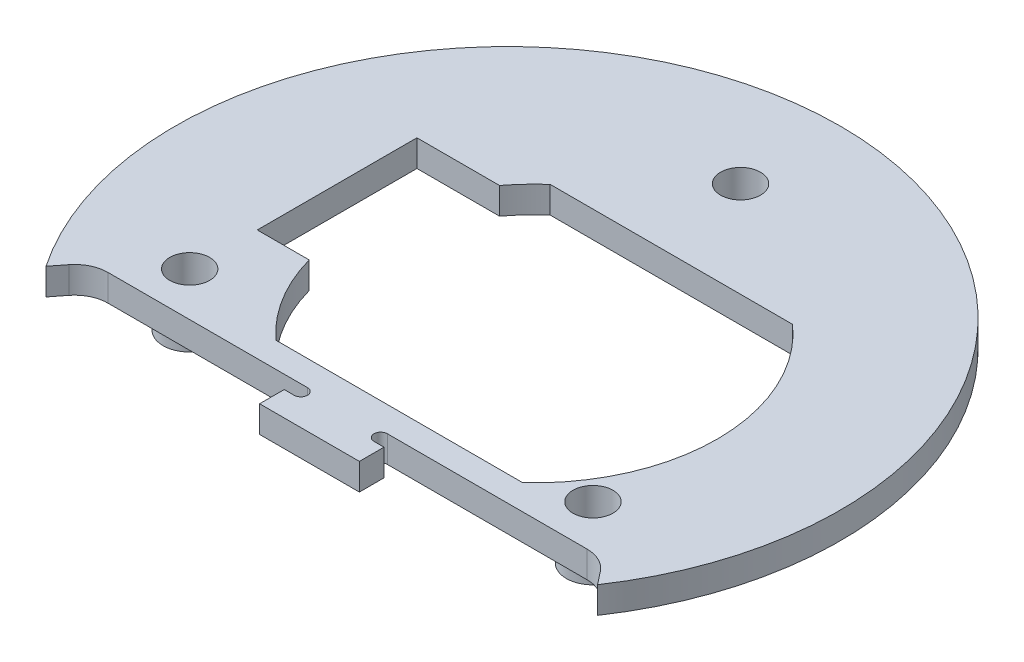
from build123d import *

# Parameters (mm, degrees)
SKETCH1_R           = 50
BOSS_EXTRUDE1_DEPTH = 4
CUT_EXTRUDE1_START  = -1
SKETCH2_R           = 3
CUT_EXTRUDE1_DEPTH  = 6
CIRPATTERN1_COUNT   = 3
SKETCH3_R           = 4
BOSS_EXTRUDE3_DEPTH = 4
SKETCH4_R           = 3
CUT_EXTRUDE2_DEPTH  = 5
CIRPATTERN2_COUNT   = 3
CUT_EXTRUDE4_DEPTH  = 5
CUT_EXTRUDE5_DEPTH  = 9


with BuildPart() as part:
    # Sketch1 → Boss-Extrude1 (new body)
    with BuildSketch(Plane(origin=(0, 0, 0), x_dir=(1, 0, 0), z_dir=(0, 1, 0))):
        Circle(SKETCH1_R)
    extrude(amount=BOSS_EXTRUDE1_DEPTH)

    # Sketch2 → Cut-Extrude1 (cut)
    with BuildSketch(Plane(origin=(0, 0, 0), x_dir=(1, 0, 0), z_dir=(0, 1, 0)).offset(CUT_EXTRUDE1_START)):
        with Locations((0, 35)):
            Circle(SKETCH2_R)
    cut_extrude1 = extrude(amount=CUT_EXTRUDE1_DEPTH, mode=Mode.SUBTRACT)

    # CirPattern1: Cut-Extrude1 ×3 about axis
    cirpattern1_axis = Axis((0, 0, 0), (0, 1, 0))
    for i in range(1, CIRPATTERN1_COUNT):
        add(cut_extrude1.rotate(cirpattern1_axis, i * 360 / CIRPATTERN1_COUNT), mode=Mode.SUBTRACT)

    # Sketch3 → Boss-Extrude3 (add)
    with BuildSketch(Plane.XZ):
        with Locations((0, -35)):
            Circle(SKETCH3_R)
    boss_extrude3 = extrude(amount=BOSS_EXTRUDE3_DEPTH)

    # Sketch4 → Cut-Extrude2 (cut, through all)
    with BuildSketch(Plane.XZ):
        with Locations((0, -35)):
            Circle(SKETCH4_R)
    cut_extrude2 = extrude(amount=CUT_EXTRUDE2_DEPTH, mode=Mode.SUBTRACT)

    # CirPattern2: Boss-Extrude3, Cut-Extrude2 ×3 about axis
    cirpattern2_axis = Axis((0, 0, 0), (0, 1, 0))
    for i in range(1, CIRPATTERN2_COUNT):
        add(boss_extrude3.rotate(cirpattern2_axis, i * 360 / CIRPATTERN2_COUNT))
        add(cut_extrude2.rotate(cirpattern2_axis, i * 360 / CIRPATTERN2_COUNT), mode=Mode.SUBTRACT)

    # Sketch5 → Cut-Extrude4 (cut, through all)
    with BuildSketch(Plane(origin=(0, 0, 0), x_dir=(1, 0, 0), z_dir=(0, 1, 0))):
        with BuildLine():
            Line((-36, -24.1), (-6, -24.1))
            ThreePointArc((-6, -24.1), (-5, -25.1), (-6, -26.1))
            Line((-6, -26.1), (-7.5, -26.1))
            Line((-7.5, -26.1), (-7.5, -29.8))
            Line((-7.5, -29.8), (7.5, -29.8))
            Line((7.5, -29.8), (7.5, -26.1))
            Line((7.5, -26.1), (6, -26.1))
            ThreePointArc((6, -26.1), (5, -25.1), (6, -24.1))
            Line((6, -24.1), (36, -24.1))
            ThreePointArc((36, -24.1), (38.18825044, -24.604273138), (39.935110512, -26.015375995))
            Line((39.935110512, -26.015375995), (41.455250321, -27.954645783))
            ThreePointArc((41.455250321, -27.954645783), (0, -50), (-41.455250321, -27.954645783))
            Line((-41.455250321, -27.954645783), (-39.935110512, -26.015375995))
            ThreePointArc((-39.935110512, -26.015375995), (-38.18825044, -24.604273138), (-36, -24.1))
        make_face()
    extrude(amount=CUT_EXTRUDE4_DEPTH, mode=Mode.SUBTRACT)

    # Sketch6 → Cut-Extrude5 (cut, through all)
    with BuildSketch(Plane(origin=(0, 4, 0), x_dir=(1, 0, 0), z_dir=(0, 1, 0))):
        with BuildLine():
            Line((-30.3, -7.35), (-30.3, 16.65))
            Line((-30.3, 16.65), (-17.886696873, 16.65))
            ThreePointArc((-17.886696873, 16.65), (-16.149299311, 18.715120553), (-14.217848391, 20.6))
            Line((-14.217848391, 20.6), (22.217848391, 20.6))
            ThreePointArc((22.217848391, 20.6), (31.499084727, 0.224363896), (22.5515498, -20.3))
            Line((22.5515498, -20.3), (-14.5515498, -20.3))
            ThreePointArc((-14.5515498, -20.3), (-19.437717402, -14.384832394), (-22.499575468, -7.35))
            Line((-22.499575468, -7.35), (-30.3, -7.35))
        make_face()
    extrude(amount=-CUT_EXTRUDE5_DEPTH, mode=Mode.SUBTRACT)


solid = part.part
